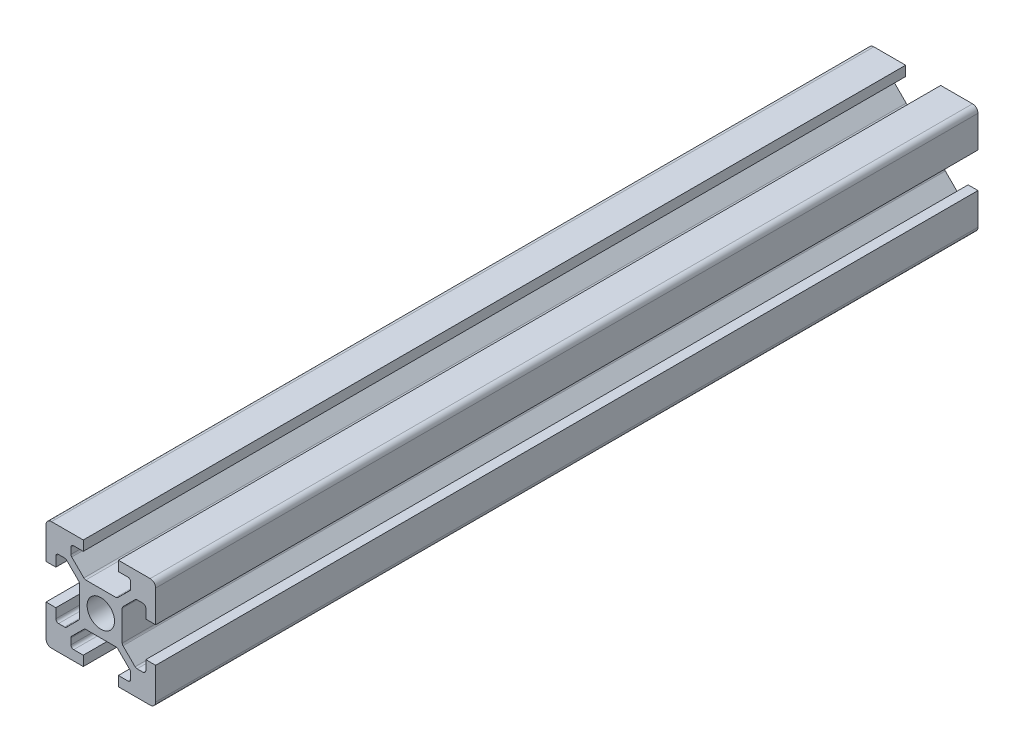
from build123d import *

# Parameters (mm, degrees)
SKETCH1_R           = 2.5
BOSS_EXTRUDE1_DEPTH = 150
FILLET1_R           = 1
FILLET2_R           = 0.5
FILLET3_R           = 0.5
FILLET4_R           = 0.5
FILLET5_R           = 0.5


with BuildPart() as part:
    # Sketch1 → Boss-Extrude1 (new body)
    with BuildSketch(Plane.XY):
        Polygon((13.2, 0), (13.2, 1.8), (15.45, 1.8), (15.45, 3.6), (12.95, 6.1), (7.05, 6.1), (4.55, 3.6), (4.55, 1.8), (6.8, 1.8), (6.8, 0), (0, 0), (0, 6.8), (1.8, 6.8), (1.8, 4.55), (3.6, 4.55), (6.1, 7.05), (6.1, 12.95), (3.6, 15.45), (1.8, 15.45), (1.8, 13.2), (0, 13.2), (0, 20), (6.8, 20), (6.8, 18.2), (4.55, 18.2), (4.55, 16.4), (7.05, 13.9), (12.95, 13.9), (15.45, 16.4), (15.45, 18.2), (13.2, 18.2), (13.2, 20), (20, 20), (20, 13.2), (18.2, 13.2), (18.2, 15.45), (16.4, 15.45), (13.9, 12.95), (13.9, 7.05), (16.4, 4.55), (18.2, 4.55), (18.2, 6.8), (20, 6.8), (20, 0), align=None)
        with Locations((10, 10)):
            Circle(SKETCH1_R, mode=Mode.SUBTRACT)
    extrude(amount=BOSS_EXTRUDE1_DEPTH)

    # Fillet1
    fillet1_edges = [part.edges().sort_by_distance(p)[0] for p in [
        (0, 0, 75),
        (0, 20, 75),
        (20, 20, 75),
        (20, 0, 75),
    ]]
    fillet(fillet1_edges, radius=FILLET1_R)

    # Fillet2
    fillet2_edges = [part.edges().sort_by_distance(p)[0] for p in [
        (4.55, 18.2, 75),
        (4.55, 16.4, 75),
        (7.05, 13.9, 75),
        (12.95, 13.9, 75),
        (15.45, 16.4, 75),
        (15.45, 18.2, 75),
    ]]
    fillet(fillet2_edges, radius=FILLET2_R)

    # Fillet3
    fillet3_edges = [part.edges().sort_by_distance(p)[0] for p in [
        (18.2, 15.45, 75),
        (16.4, 15.45, 75),
        (13.9, 12.95, 75),
        (13.9, 7.05, 75),
        (16.4, 4.55, 75),
        (18.2, 4.55, 75),
    ]]
    fillet(fillet3_edges, radius=FILLET3_R)

    # Fillet4
    fillet4_edges = [part.edges().sort_by_distance(p)[0] for p in [
        (1.8, 4.55, 75),
        (3.6, 4.55, 75),
        (6.1, 7.05, 75),
        (6.1, 12.95, 75),
        (3.6, 15.45, 75),
        (1.8, 15.45, 75),
    ]]
    fillet(fillet4_edges, radius=FILLET4_R)

    # Fillet5
    fillet5_edges = [part.edges().sort_by_distance(p)[0] for p in [
        (15.45, 1.8, 75),
        (15.45, 3.6, 75),
        (12.95, 6.1, 75),
        (7.05, 6.1, 75),
        (4.55, 3.6, 75),
        (4.55, 1.8, 75),
    ]]
    fillet(fillet5_edges, radius=FILLET5_R)


solid = part.part
